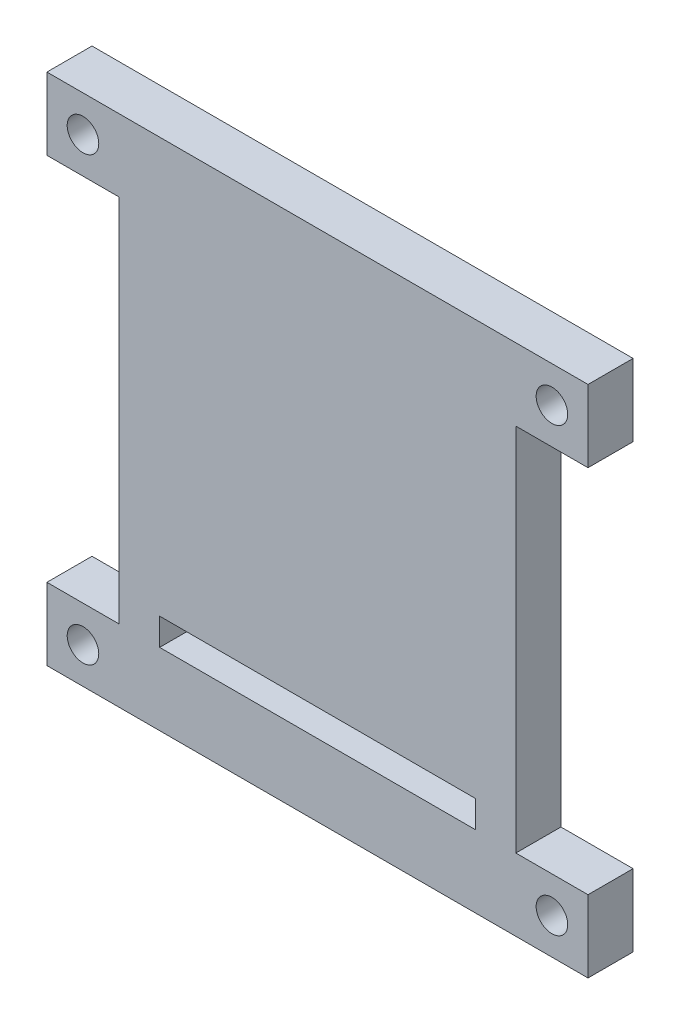
from build123d import *

# Parameters (mm, degrees)
SKETCH_1_R          = 1.75
EXTRUDE_1_DEPTH     = 5
CUT_EXTRUDE_1_REACH = 7
SKETCH_2_W          = 35
SKETCH_2_H          = 3


with BuildPart() as part:
    # 草圖1 → 填料-伸長1 (new body)
    with BuildSketch(Plane.XY):
        Polygon((-30, 28.5), (-30, 20.5), (-22, 20.5), (-22, -20.5), (-30, -20.5), (-30, -28.5), (30, -28.5), (30, -20.5), (22, -20.5), (22, 20.5), (30, 20.5), (30, 28.5), align=None)
        with Locations((-26, 24.5)):
            Circle(SKETCH_1_R, mode=Mode.SUBTRACT)
        with Locations((26, 24.5)):
            Circle(SKETCH_1_R, mode=Mode.SUBTRACT)
        with Locations((-26, -24.5)):
            Circle(SKETCH_1_R, mode=Mode.SUBTRACT)
        with Locations((26, -24.5)):
            Circle(SKETCH_1_R, mode=Mode.SUBTRACT)
    extrude(amount=EXTRUDE_1_DEPTH)

    # 草圖2 → 除料-伸長1 (cut, up to next)
    with BuildSketch(Plane.XY.offset(5), mode=Mode.PRIVATE) as cut_extrude_1_sk1:
        with Locations((0, -19)):
            Rectangle(SKETCH_2_W, SKETCH_2_H)
    cut_extrude_1_tool1 = extrude(cut_extrude_1_sk1.sketch, amount=-CUT_EXTRUDE_1_REACH, mode=Mode.PRIVATE) & part.part
    add(cut_extrude_1_tool1.solids().sort_by_distance((0, -19, 5))[0], mode=Mode.SUBTRACT)


solid = part.part
